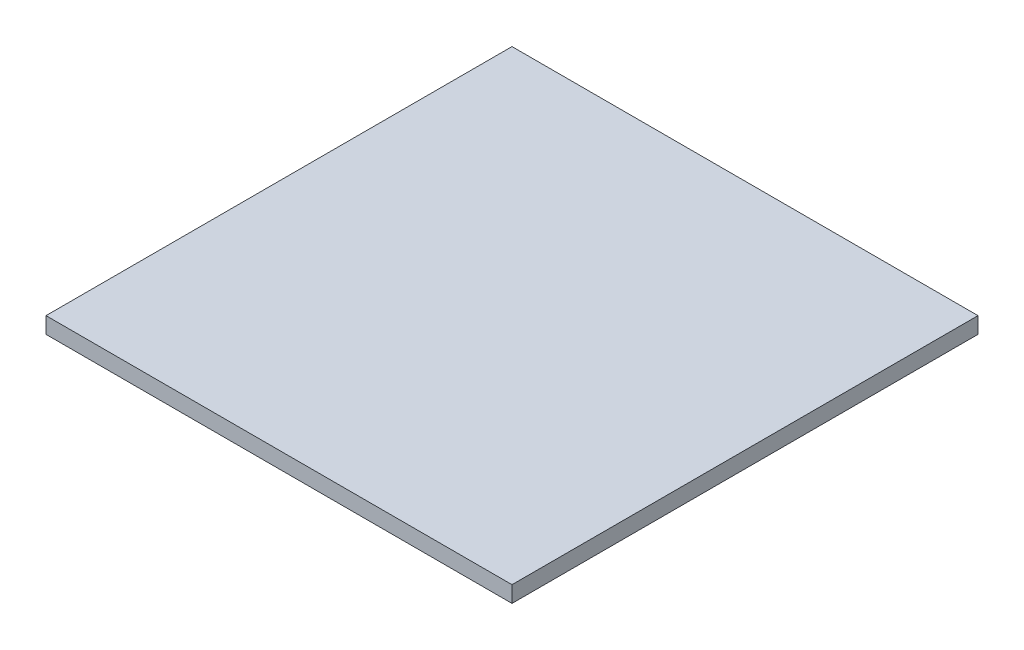
from build123d import *

# Parameters (mm, degrees)
SKETCH1_W           = 35
SKETCH1_H           = 35
BOSS_EXTRUDE1_DEPTH = 1.22


with BuildPart() as part:
    # Sketch1 → Boss-Extrude1 (new body)
    with BuildSketch(Plane(origin=(0, 0, 0), x_dir=(1, 0, 0), z_dir=(0, 1, 0))):
        Rectangle(SKETCH1_W, SKETCH1_H)
    extrude(amount=BOSS_EXTRUDE1_DEPTH)


solid = part.part
